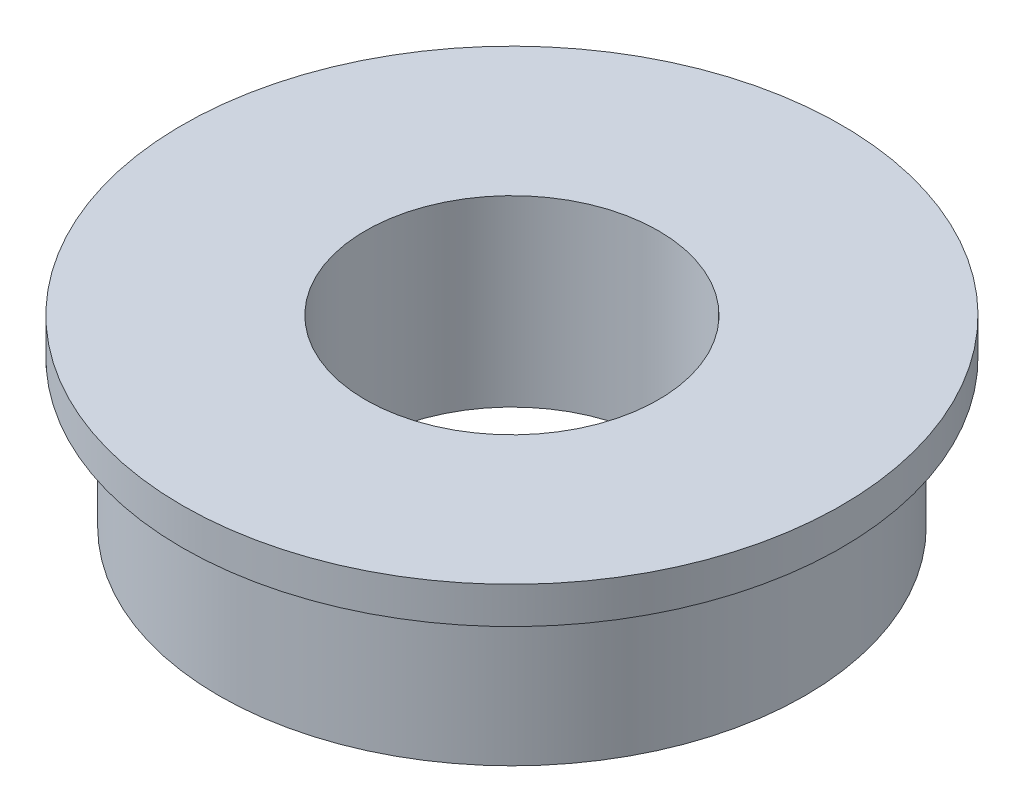
from build123d import *

# Parameters (mm, degrees)
SKETCH2_R           = 8
SKETCH2_R_2         = 4
BOSS_EXTRUDE1_DEPTH = 2.5
SKETCH3_R           = 9
BOSS_EXTRUDE3_DEPTH = 1
SKETCH5_R           = 4
CUT_EXTRUDE1_DEPTH  = 6


with BuildPart() as part:
    # Sketch2 → Boss-Extrude1 (new body, symmetric)
    with BuildSketch(Plane(origin=(0, 0, 0), x_dir=(1, 0, 0), z_dir=(0, 1, 0))):
        Circle(SKETCH2_R)
        Circle(SKETCH2_R_2, mode=Mode.SUBTRACT)
    extrude(amount=BOSS_EXTRUDE1_DEPTH, both=True)

    # Sketch3 → Boss-Extrude3 (add)
    with BuildSketch(Plane(origin=(0, 2.5, 0), x_dir=(1, 0, 0), z_dir=(0, 1, 0))):
        Circle(SKETCH3_R)
    extrude(amount=-BOSS_EXTRUDE3_DEPTH)

    # Sketch5 → Cut-Extrude1 (cut, through all)
    with BuildSketch(Plane.XZ.offset(2.5)):
        Circle(SKETCH5_R)
    extrude(amount=-CUT_EXTRUDE1_DEPTH, mode=Mode.SUBTRACT)


solid = part.part
